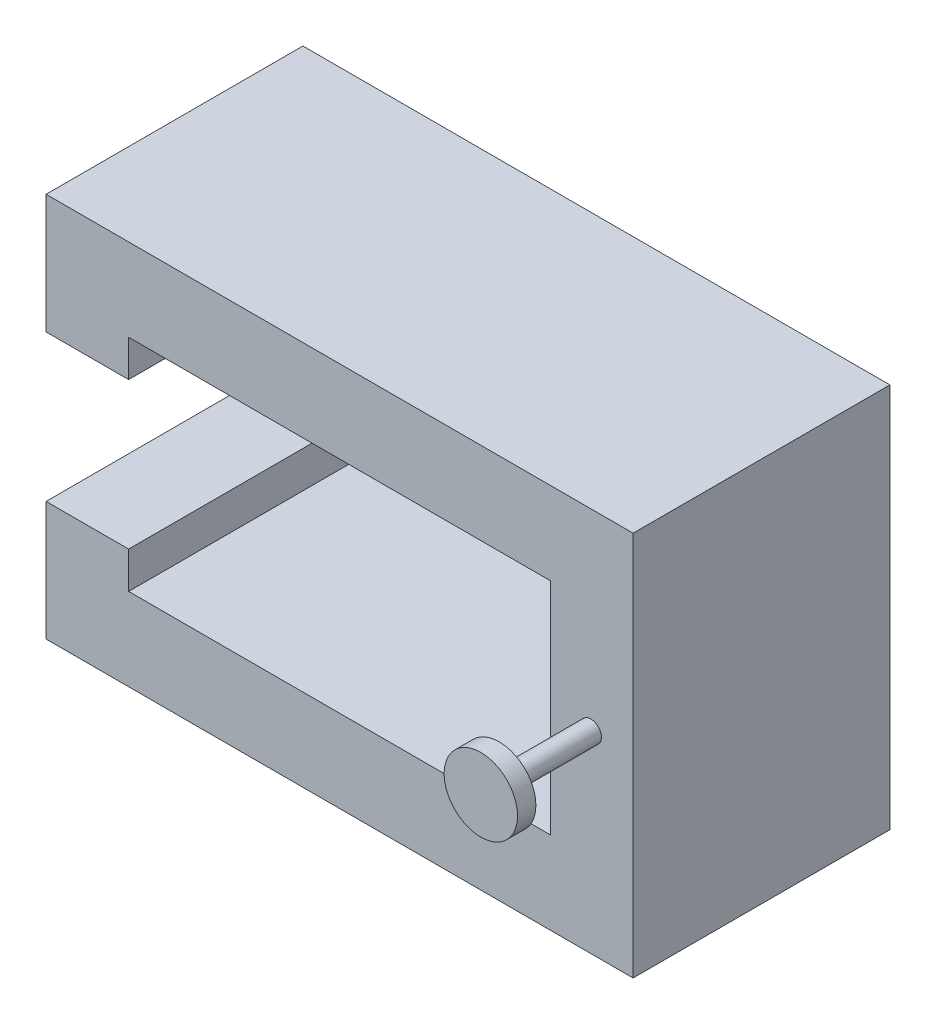
from build123d import *

# Parameters (mm, degrees)
BOSS_EXTRUDE3_DEPTH = 14
SKETCH4_R           = 0.575
BOSS_EXTRUDE4_DEPTH = 5
SKETCH5_R           = 2
BOSS_EXTRUDE5_DEPTH = 1


with BuildPart() as part:
    # Sketch1 → Boss-Extrude3 (new body)
    with BuildSketch(Plane.XY):
        Polygon((0, 0), (32, 0), (32, 21), (0, 21), (0, 14.5), (4.5, 14.5), (4.5, 16.5), (27.5, 16.5), (27.5, 4.5), (4.5, 4.5), (4.5, 6.5), (0, 6.5), align=None)
    extrude(amount=BOSS_EXTRUDE3_DEPTH)

    # Sketch4 → Boss-Extrude4 (add)
    with BuildSketch(Plane.XY.offset(14)):
        with Locations((29.7, 10.5)):
            Circle(SKETCH4_R)
    extrude(amount=BOSS_EXTRUDE4_DEPTH)

    # Sketch5 → Boss-Extrude5 (add)
    with BuildSketch(Plane.XY.offset(19)):
        with Locations((29.7, 10.5)):
            Circle(SKETCH5_R)
    extrude(amount=BOSS_EXTRUDE5_DEPTH)


solid = part.part
